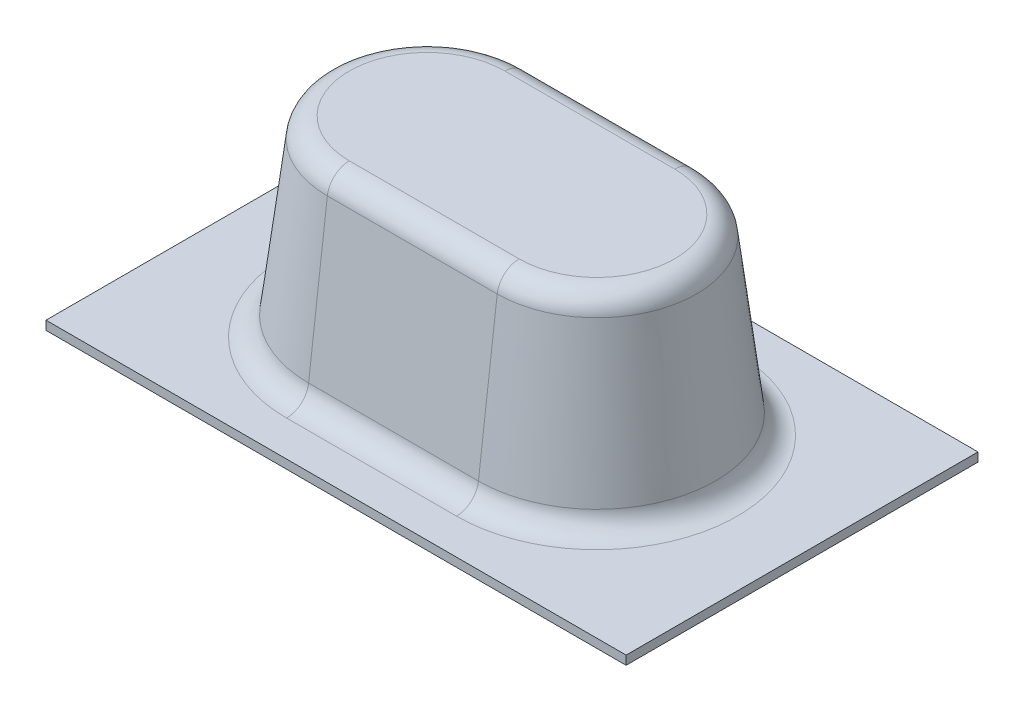
from build123d import *

# Parameters (mm, degrees)
SKETCH1_W           = 33.3
SKETCH1_H           = 20.2
BOSS_EXTRUDE1_DEPTH = 0.508
BOSS_EXTRUDE2_DEPTH = 11.5
BOSS_EXTRUDE2_TAPER = 7
FILLET1_R           = 1.27
FILLET4_R           = 1.27


with BuildPart() as part:
    # Sketch1 → Boss-Extrude1 (new body)
    with BuildSketch(Plane(origin=(0, 0, 0), x_dir=(1, 0, 0), z_dir=(0, 1, 0))):
        Rectangle(SKETCH1_W, SKETCH1_H)
    extrude(amount=BOSS_EXTRUDE1_DEPTH)

    # Sketch2 → Boss-Extrude2 (add)
    with BuildSketch(Plane(origin=(0, 0, 0), x_dir=(1, 0, 0), z_dir=(0, 1, 0))):
        with BuildLine():
            ThreePointArc((-4.875, 7), (-11.875, 0), (-4.875, -7))
            Line((-4.875, -7), (4.875, -7))
            ThreePointArc((4.875, -7), (11.875, 0), (4.875, 7))
            Line((4.875, 7), (-4.875, 7))
        make_face()
    extrude(amount=BOSS_EXTRUDE2_DEPTH, taper=BOSS_EXTRUDE2_TAPER)

    # Fillet1
    fillet1_edges = [part.edges().sort_by_distance(p)[0] for p in [
        (10.46297755, 11.5, 0),
        (0, 11.5, -5.58797755),
        (-10.46297755, 11.5, 0),
        (0, 11.5, 5.58797755),
    ]]
    fillet(fillet1_edges, radius=FILLET1_R)

    # Fillet4
    fillet4_edges = [part.edges().sort_by_distance(p)[0] for p in [
        (11.812625443, 0.508, 0),
        (0, 0.508, -6.937625443),
        (-11.812625443, 0.508, 0),
        (0, 0.508, 6.937625443),
    ]]
    fillet(fillet4_edges, radius=FILLET4_R)


solid = part.part
